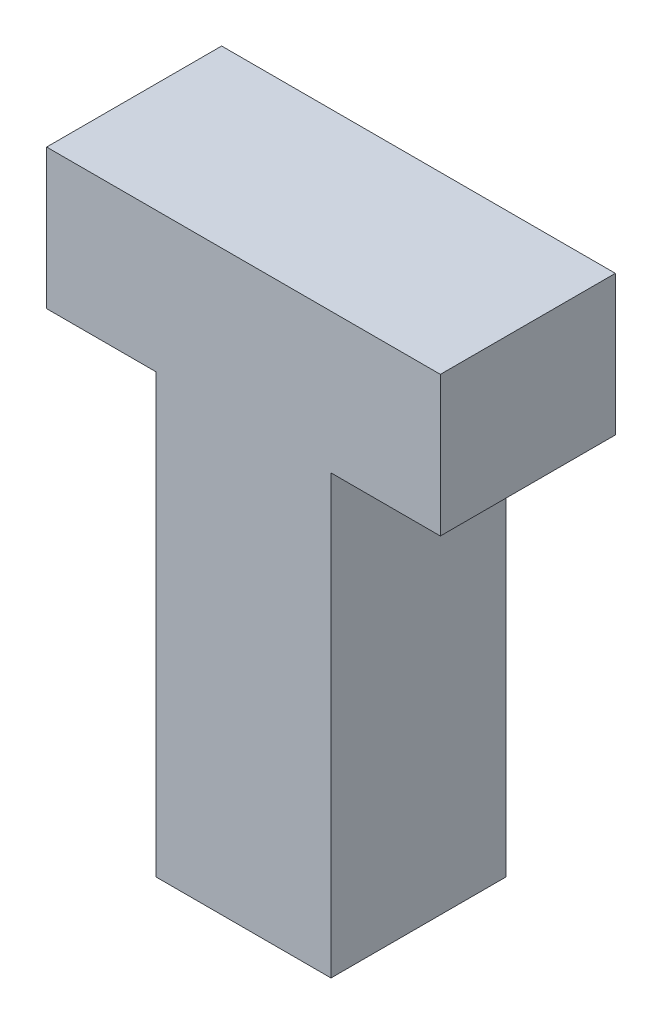
from build123d import *

# Parameters (mm, degrees)
EXTRUDE_1_DEPTH = 1


with BuildPart() as part:
    # Эскиз1 → Бобышка-Вытянуть1 (new body, symmetric)
    with BuildSketch(Plane.XY):
        Polygon((1, 0), (-1, 0), (-1, 5), (-2.25, 5), (-2.25, 6.6), (0, 6.6), (2.25, 6.6), (2.25, 5), (1, 5), align=None)
    extrude(amount=EXTRUDE_1_DEPTH, both=True)


solid = part.part
